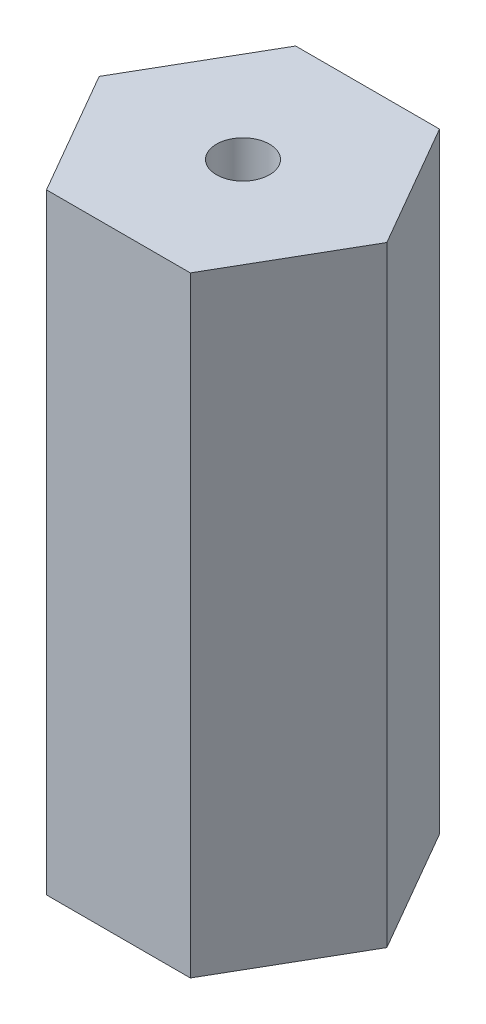
from build123d import *

# Parameters (mm, degrees)
BOSS_EXTRUDE1_DEPTH = 29.90078
SKETCH2_R           = 1.3
CUT_EXTRUDE1_DEPTH  = 30.90078


with BuildPart() as part:
    # Sketch1 → Boss-Extrude1 (new body)
    with BuildSketch(Plane(origin=(0, 0, 0), x_dir=(1, 0, 0), z_dir=(0, 1, 0))):
        Polygon((3.521836642, 6.1), (-3.521836642, 6.1), (-7.043673284, 0), (-3.521836642, -6.1), (3.521836642, -6.1), (7.043673284, 0), align=None)
    extrude(amount=BOSS_EXTRUDE1_DEPTH)

    # Sketch2 → Cut-Extrude1 (cut, through all)
    with BuildSketch(Plane(origin=(0, 29.90078, 0), x_dir=(1, 0, 0), z_dir=(0, 1, 0))):
        Circle(SKETCH2_R)
    extrude(amount=-CUT_EXTRUDE1_DEPTH, mode=Mode.SUBTRACT)


solid = part.part
